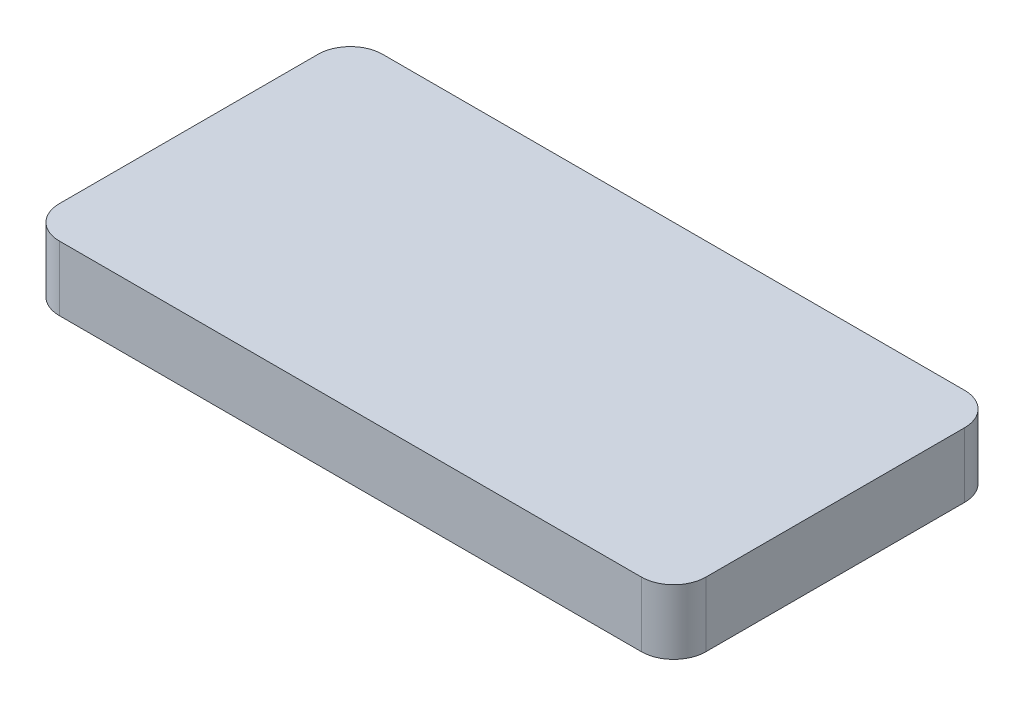
from build123d import *

# Parameters (mm, degrees)
BOSS_EXTRUDE1_DEPTH = 10
SKETCH2_W           = 19.927758229
SKETCH2_H           = 16.606465191
BOSS_EXTRUDE2_DEPTH = 6


with BuildPart() as part:
    # Sketch1 → Boss-Extrude1 (new body)
    with BuildSketch(Plane(origin=(0, 0, 0), x_dir=(1, 0, 0), z_dir=(0, 1, 0))):
        with BuildLine():
            Line((79.305838263, 49.982687997), (-10.694161737, 49.982687997))
            ThreePointArc((-10.694161737, 49.982687997), (-14.229695643, 48.518221903), (-15.694161737, 44.982687997))
            Line((-15.694161737, 44.982687997), (-15.694161737, 4.982687997))
            ThreePointArc((-15.694161737, 4.982687997), (-14.229695643, 1.447154091), (-10.694161737, -0.017312003))
            Line((-10.694161737, -0.017312003), (79.305838263, -0.017312003))
            ThreePointArc((79.305838263, -0.017312003), (82.841372169, 1.447154091), (84.305838263, 4.982687997))
            Line((84.305838263, 4.982687997), (84.305838263, 44.982687997))
            ThreePointArc((84.305838263, 44.982687997), (82.841372169, 48.518221903), (79.305838263, 49.982687997))
        make_face()
    extrude(amount=BOSS_EXTRUDE1_DEPTH)


with BuildPart() as body_2:
    # Sketch2 → Boss-Extrude2 (new body)
    with BuildSketch(Plane(origin=(0, 10, 0), x_dir=(1, 0, 0), z_dir=(0, 1, 0))):
        with Locations((-0.730282622, 13.285920593)):
            Rectangle(SKETCH2_W, SKETCH2_H)
    extrude(amount=-BOSS_EXTRUDE2_DEPTH)


solid = Compound([part.part, body_2.part])
